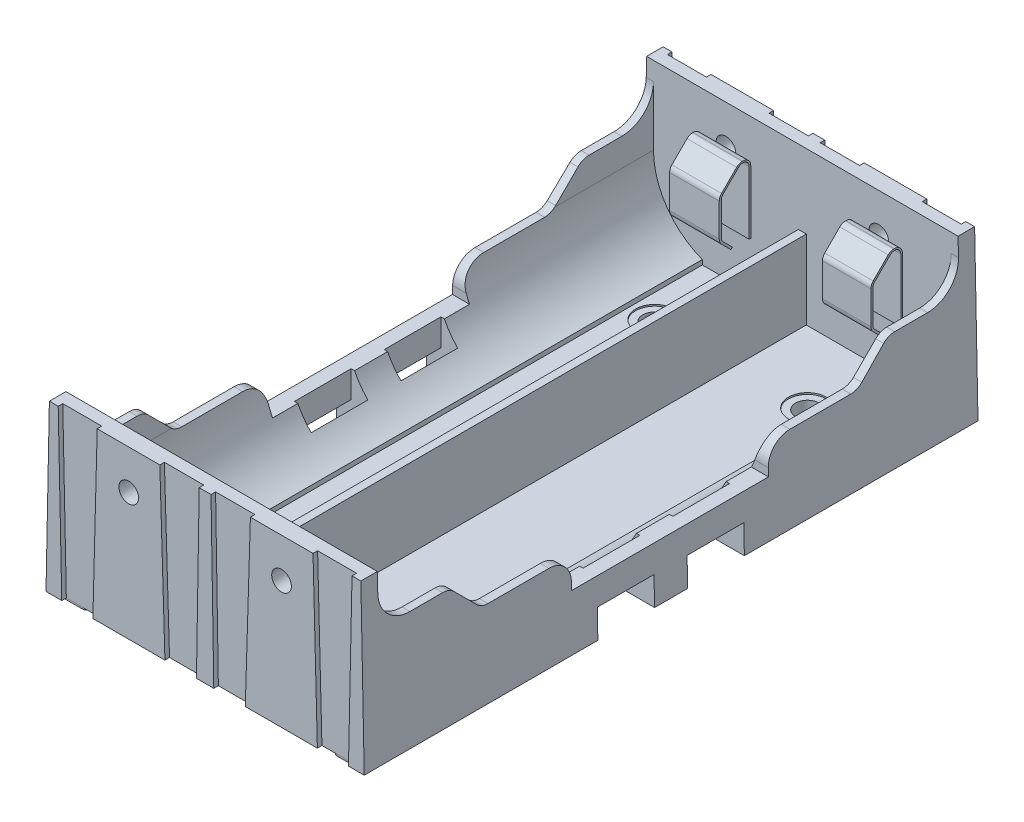
from build123d import *

# Parameters (mm, degrees)
BOSS_EXTRU_1_DEPTH       = 73.72
BOSS_EXTRU_2_DEPTH       = 2.1
BOSS_EXTRU_3_DEPTH       = 2.1
CONG_1_R                 = 4
ENL_V_START              = 17.890763
ENL_V_MAT_EXTRU_1_DEPTH  = 2.167345
ENL_V_START_2            = -20.058108
ENL_V_MAT_EXTRU_2_DEPTH  = 2.167345
ENL_V_START_3            = 16.2
ESQUISSE6_W              = 7.2
ESQUISSE6_H              = 7.148183782
ENL_V_MAT_EXTRU_3_DEPTH  = 4
ENL_V_START_4            = -20.2
ESQUISSE6_2_W            = 7.2
ESQUISSE6_2_H            = 7.148183782
ENL_V_MAT_EXTRU_4_DEPTH  = 4
ESQUISSE7_W              = 2.127027027
ESQUISSE7_H              = 7.2
ENL_V_MAT_EXTRU_5_DEPTH  = 22.14
CONG_2_R                 = 2
CONG_3_R                 = 2.8
ESQUISSE8_R              = 3
BOSS_EXTRU_4_DEPTH       = 0.22
ESQUISSE9_R              = 1.5
ENL_V_MAT_EXTRU_6_DEPTH  = 22.36
ENL_V_MAT_EXTRU_7_DEPTH  = 0.58
ENL_V_START_5            = -77.92
ENL_V_MAT_EXTRU_8_DEPTH  = 0.58
ESQUISSE11_R             = 2.4
ENL_V_MAT_EXTRU_9_DEPTH  = 0.2
BOSS_EXTRU_5_START       = 6
ESQUISSE12_W             = 6.3
ESQUISSE12_H             = 4
ESQUISSE12_W_2           = 6.15
BOSS_EXTRU_5_DEPTH       = 9
CHANFREIN1_SIZE          = 2.5
CHANFREIN2_SIZE          = 1.5
CONG_4_R                 = 1
ENL_V_MAT_EXTRU_10_REACH = 34.9
ENL_V_START_6            = -25.55
ENL_V_MAT_EXTRU_11_DEPTH = 6.3
ESQUISSE14_R             = 1.25
ENL_V_MAT_EXTRU_12_DEPTH = 2.1
ESQUISSE14_2_R           = 1.25
ENL_V_MAT_EXTRU_13_DEPTH = 2.1


with BuildPart() as part:
    # Esquisse1 → Boss.-Extru.1 (new body)
    with BuildSketch(Plane.XY):
        with BuildLine():
            Line((-19.9, 14.8), (-20.2, 0))
            Line((-20.2, 0), (0, 0))
            Line((0, 0), (0, 11.74))
            Line((0, 11.74), (-0.5, 11.74))
            Line((-0.5, 11.74), (-0.5, 1.74))
            Line((-0.5, 1.74), (-12.7, 1.74))
            Line((-12.7, 1.74), (-12.7, 2.34))
            ThreePointArc((-12.7, 2.34), (-17.19797428, 5.832963152), (-18.9, 11.267636339))
            Line((-18.9, 11.267636339), (-18.9, 14.8))
            Line((-18.9, 14.8), (-19.9, 14.8))
        make_face()
        with BuildLine():
            Line((0, 11.74), (0, 0))
            Line((0, 0), (20.2, 0))
            Line((20.2, 0), (19.9, 14.8))
            Line((19.9, 14.8), (18.9, 14.8))
            Line((18.9, 14.8), (18.9, 11.267636339))
            ThreePointArc((18.9, 11.267636339), (17.19797428, 5.832963152), (12.7, 2.34))
            Line((12.7, 2.34), (12.7, 1.74))
            Line((12.7, 1.74), (0.5, 1.74))
            Line((0.5, 1.74), (0.5, 11.74))
            Line((0.5, 11.74), (0, 11.74))
        make_face()
    extrude(amount=BOSS_EXTRU_1_DEPTH)

    # Esquisse2 → Boss.-Extru.2 (add)
    with BuildSketch(Plane.XY.offset(73.72)):
        Polygon((-20.2, 0), (20.2, 0), (19.771486486, 21.14), (-19.771486486, 21.14), align=None)
    extrude(amount=BOSS_EXTRU_2_DEPTH)

    # Esquisse3 → Boss.-Extru.3 (add)
    with BuildSketch(Plane(origin=(0, 0, 0), x_dir=(-1, 0, 0), z_dir=(0, 0, -1))):
        Polygon((-20.2, 0), (20.2, 0), (19.771486486, 21.14), (-19.771486486, 21.14), align=None)
    extrude(amount=BOSS_EXTRU_3_DEPTH)

    # Cong_1
    cong_1_edges = [part.edges().sort_by_distance(p)[0] for p in [
        (19.4, 14.8, 0),
        (-19.4, 14.8, 0),
        (-19.4, 14.8, 73.72),
        (19.4, 14.8, 73.72),
    ]]
    fillet(cong_1_edges, radius=CONG_1_R)

    # Esquisse4 → Enl_v. mat.-Extru.1 (cut)
    with BuildSketch(Plane(origin=(0, 0, 0), x_dir=(0, 0, -1), z_dir=(1, 0, 0)).offset(ENL_V_START)):
        Polygon((-64.72, 14.8), (-60.72, 10.8), (-49.36, 10.8), (-49.36, 7), (-24.36, 7), (-24.36, 10.8), (-13, 10.8), (-9, 14.8), align=None)
    extrude(amount=ENL_V_MAT_EXTRU_1_DEPTH, mode=Mode.SUBTRACT)

    # Esquisse4_2 → Enl_v. mat.-Extru.2 (cut)
    with BuildSketch(Plane(origin=(0, 0, 0), x_dir=(0, 0, -1), z_dir=(1, 0, 0)).offset(ENL_V_START_2)):
        Polygon((-64.72, 14.8), (-60.72, 10.8), (-49.36, 10.8), (-49.36, 7), (-24.36, 7), (-24.36, 10.8), (-13, 10.8), (-9, 14.8), align=None)
    extrude(amount=ENL_V_MAT_EXTRU_2_DEPTH, mode=Mode.SUBTRACT)

    # Esquisse6 → Enl_v. mat.-Extru.3 (cut)
    with BuildSketch(Plane(origin=(0, 0, 0), x_dir=(0, 0, -1), z_dir=(1, 0, 0)).offset(ENL_V_START_3)):
        with Locations((-42.56, 0.025908109)):
            Rectangle(ESQUISSE6_W, ESQUISSE6_H)
        with Locations((-31.16, 0.025908109)):
            Rectangle(ESQUISSE6_W, ESQUISSE6_H)
    extrude(amount=ENL_V_MAT_EXTRU_3_DEPTH, mode=Mode.SUBTRACT)

    # Esquisse6_2 → Enl_v. mat.-Extru.4 (cut)
    with BuildSketch(Plane(origin=(0, 0, 0), x_dir=(0, 0, -1), z_dir=(1, 0, 0)).offset(ENL_V_START_4)):
        with Locations((-42.56, 0.025908109)):
            Rectangle(ESQUISSE6_2_W, ESQUISSE6_2_H)
        with Locations((-31.16, 0.025908109)):
            Rectangle(ESQUISSE6_2_W, ESQUISSE6_2_H)
    extrude(amount=ENL_V_MAT_EXTRU_4_DEPTH, mode=Mode.SUBTRACT)

    # Esquisse7 → Enl_v. mat.-Extru.5 (cut, through all)
    with BuildSketch(Plane.XZ):
        with Locations((17.263513514, 42.56)):
            Rectangle(ESQUISSE7_W, ESQUISSE7_H)
        with Locations((-17.263513514, 42.56)):
            Rectangle(ESQUISSE7_W, ESQUISSE7_H)
        with Locations((17.263513514, 31.16)):
            Rectangle(ESQUISSE7_W, ESQUISSE7_H)
        with Locations((-17.263513514, 31.16)):
            Rectangle(ESQUISSE7_W, ESQUISSE7_H)
    extrude(amount=-ENL_V_MAT_EXTRU_5_DEPTH, mode=Mode.SUBTRACT)

    # Cong_2
    cong_2_edges = [part.edges().sort_by_distance(p)[0] for p in [
        (-19.4, 14.8, 9),
        (19.4, 14.8, 9),
        (19.4, 14.8, 64.72),
        (-19.4, 14.8, 64.72),
        (-19.434798938, 10.8, 60.72),
        (19.434798938, 10.8, 60.72),
        (19.434798938, 10.8, 13),
        (-19.434798938, 10.8, 13),
    ]]
    fillet(cong_2_edges, radius=CONG_2_R)

    # Cong_3
    cong_3_edges = [part.edges().sort_by_distance(p)[0] for p in [
        (19.434798938, 10.8, 49.36),
        (19.434798938, 10.8, 24.36),
        (-19.434798938, 10.8, 24.36),
        (-19.434798938, 10.8, 49.36),
    ]]
    fillet(cong_3_edges, radius=CONG_3_R)

    # Esquisse8 → Boss.-Extru.4 (add)
    with BuildSketch(Plane.XZ):
        with Locations((-9.7, 64.66)):
            Circle(ESQUISSE8_R)
        with Locations((9.7, 64.66)):
            Circle(ESQUISSE8_R)
        with Locations((9.7, 9.06)):
            Circle(ESQUISSE8_R)
        with Locations((-9.7, 9.06)):
            Circle(ESQUISSE8_R)
        with BuildLine():
            Line((-19.1, 75.22), (-16.16, 75.22))
            ThreePointArc((-16.16, 75.22), (-15.66, 74.72), (-16.16, 74.22))
            Line((-16.16, 74.22), (-18.5, 74.22))
            ThreePointArc((-18.5, 74.22), (-18.570710678, 74.190710678), (-18.6, 74.12))
            Line((-18.6, 74.12), (-18.6, 73.42))
            ThreePointArc((-18.6, 73.42), (-19.1, 72.92), (-19.6, 73.42))
            Line((-19.6, 73.42), (-19.6, 74.72))
            ThreePointArc((-19.6, 74.72), (-19.453553391, 75.073553391), (-19.1, 75.22))
        make_face()
        with BuildLine():
            Line((18.6, 73.42), (18.6, 74.12))
            ThreePointArc((18.6, 74.12), (18.570710678, 74.190710678), (18.5, 74.22))
            Line((18.5, 74.22), (16.16, 74.22))
            ThreePointArc((16.16, 74.22), (15.66, 74.72), (16.16, 75.22))
            Line((16.16, 75.22), (19.1, 75.22))
            ThreePointArc((19.1, 75.22), (19.453553391, 75.073553391), (19.6, 74.72))
            Line((19.6, 74.72), (19.6, 73.42))
            ThreePointArc((19.6, 73.42), (19.1, 72.92), (18.6, 73.42))
        make_face()
        with BuildLine():
            Line((19.1, -1.5), (16.16, -1.5))
            ThreePointArc((16.16, -1.5), (15.66, -1), (16.16, -0.5))
            Line((16.16, -0.5), (18.5, -0.5))
            ThreePointArc((18.5, -0.5), (18.570710678, -0.470710678), (18.6, -0.4))
            Line((18.6, -0.4), (18.6, 0.3))
            ThreePointArc((18.6, 0.3), (19.1, 0.8), (19.6, 0.3))
            Line((19.6, 0.3), (19.6, -1))
            ThreePointArc((19.6, -1), (19.453553391, -1.353553391), (19.1, -1.5))
        make_face()
        with BuildLine():
            Line((-18.6, 0.3), (-18.6, -0.4))
            ThreePointArc((-18.6, -0.4), (-18.570710678, -0.470710678), (-18.5, -0.5))
            Line((-18.5, -0.5), (-16.16, -0.5))
            ThreePointArc((-16.16, -0.5), (-15.66, -1), (-16.16, -1.5))
            Line((-16.16, -1.5), (-19.1, -1.5))
            ThreePointArc((-19.1, -1.5), (-19.453553391, -1.353553391), (-19.6, -1))
            Line((-19.6, -1), (-19.6, 0.3))
            ThreePointArc((-19.6, 0.3), (-19.1, 0.8), (-18.6, 0.3))
        make_face()
    extrude(amount=BOSS_EXTRU_4_DEPTH)

    # Esquisse9 → Enl_v. mat.-Extru.6 (cut, through all)
    with BuildSketch(Plane(origin=(0, -0.22, 0), x_dir=(-1, 0, 0), z_dir=(0, -1, 0))):
        with Locations((9.7, -64.66)):
            Circle(ESQUISSE9_R)
        with Locations((-9.7, -64.66)):
            Circle(ESQUISSE9_R)
        with Locations((-9.7, -9.06)):
            Circle(ESQUISSE9_R)
        with Locations((9.7, -9.06)):
            Circle(ESQUISSE9_R)
    extrude(amount=-ENL_V_MAT_EXTRU_6_DEPTH, mode=Mode.SUBTRACT)

    # Esquisse10 → Enl_v. mat.-Extru.7 (cut)
    with BuildSketch(Plane.XY.offset(75.82)):
        Polygon((-0.75, 21.14), (-1.1, 0), (-5.1, 0), (-5.75, 21.14), align=None)
        Polygon((-18.65, 21.14), (-18.2, 0), (-14.25, 0), (-13.7, 21.14), align=None)
        Polygon((5.1, 0), (1.1, 0), (0.75, 21.14), (5.75, 21.14), align=None)
        Polygon((18.2, 0), (14.25, 0), (13.7, 21.14), (18.65, 21.14), align=None)
    extrude(amount=-ENL_V_MAT_EXTRU_7_DEPTH, mode=Mode.SUBTRACT)

    # Esquisse10_2 → Enl_v. mat.-Extru.8 (cut)
    with BuildSketch(Plane.XY.offset(75.82).offset(ENL_V_START_5)):
        Polygon((-0.75, 21.14), (-1.1, 0), (-5.1, 0), (-5.75, 21.14), align=None)
        Polygon((-18.65, 21.14), (-18.2, 0), (-14.25, 0), (-13.7, 21.14), align=None)
        Polygon((5.1, 0), (1.1, 0), (0.75, 21.14), (5.75, 21.14), align=None)
        Polygon((18.2, 0), (14.25, 0), (13.7, 21.14), (18.65, 21.14), align=None)
    extrude(amount=ENL_V_MAT_EXTRU_8_DEPTH, mode=Mode.SUBTRACT)

    # Esquisse11 → Enl_v. mat.-Extru.9 (cut)
    with BuildSketch(Plane(origin=(0, 1.74, 0), x_dir=(1, 0, 0), z_dir=(0, 1, 0))):
        with Locations((-9.7, -9.06)):
            Circle(ESQUISSE11_R)
        with Locations((9.7, -9.06)):
            Circle(ESQUISSE11_R)
        with Locations((9.7, -64.66)):
            Circle(ESQUISSE11_R)
        with Locations((-9.7, -64.66)):
            Circle(ESQUISSE11_R)
    extrude(amount=-ENL_V_MAT_EXTRU_9_DEPTH, mode=Mode.SUBTRACT)

    # Esquisse12 → Boss.-Extru.5 (add)
    with BuildSketch(Plane(origin=(0, 1.74, 0), x_dir=(1, 0, 0), z_dir=(0, 1, 0)).offset(BOSS_EXTRU_5_START)):
        with Locations((-9.7, -71.72)):
            Rectangle(ESQUISSE12_W, ESQUISSE12_H)
        with Locations((9.625, -71.72)):
            Rectangle(ESQUISSE12_W_2, ESQUISSE12_H)
        with Locations((9.625, -2)):
            Rectangle(ESQUISSE12_W_2, ESQUISSE12_H)
        with Locations((-9.7, -2)):
            Rectangle(ESQUISSE12_W, ESQUISSE12_H)
    extrude(amount=BOSS_EXTRU_5_DEPTH)

    # Chanfrein1
    chanfrein1_edges = [part.edges().sort_by_distance(p)[0] for p in [
        (-9.7, 16.74, 69.72),
        (9.625, 16.74, 69.72),
        (9.625, 16.74, 4),
        (-9.7, 16.74, 4),
    ]]
    chamfer(chanfrein1_edges, length=CHANFREIN1_SIZE)

    # Chanfrein2
    chanfrein2_edges = [part.edges().sort_by_distance(p)[0] for p in [
        (-9.7, 7.74, 69.72),
        (9.625, 7.74, 69.72),
        (9.625, 7.74, 4),
        (-9.7, 7.74, 4),
    ]]
    chamfer(chanfrein2_edges, length=CHANFREIN2_SIZE)

    # Cong_4
    cong_4_edges = [part.edges().sort_by_distance(p)[0] for p in [
        (-9.7, 14.24, 4),
        (-9.7, 16.74, 1.5),
        (9.625, 16.74, 1.5),
        (9.625, 14.24, 4),
        (9.625, 14.24, 69.72),
        (9.625, 16.74, 72.22),
        (-9.7, 16.74, 72.22),
        (-9.7, 14.24, 69.72),
        (9.625, 9.24, 4),
        (-9.7, 9.24, 4),
        (-9.7, 9.24, 69.72),
        (9.625, 9.24, 69.72),
    ]]
    fillet(cong_4_edges, radius=CONG_4_R)

    # Esquisse13 → Enl_v. mat.-Extru.10 (cut, up to next)
    with BuildSketch(Plane(origin=(12.7, 0, 0), x_dir=(0, 0, -1), z_dir=(1, 0, 0)), mode=Mode.PRIVATE) as enl_v_mat_extru_10_sk1:
        with BuildLine():
            Line((-72.72, 16.74), (-72.72, 17.106019535))
            Line((-72.72, 17.106019535), (-73.72, 17.106019535))
            Line((-73.72, 17.106019535), (-73.72, 15.74))
            ThreePointArc((-73.72, 15.74), (-73.427106781, 16.447106781), (-72.72, 16.74))
        make_face()
    enl_v_mat_extru_10_tool1 = extrude(enl_v_mat_extru_10_sk1.sketch, amount=-ENL_V_MAT_EXTRU_10_REACH, mode=Mode.PRIVATE) & part.part
    add(enl_v_mat_extru_10_tool1.solids().sort_by_distance((12.7, 16.77281, 73.322245))[0], mode=Mode.SUBTRACT)
    # Esquisse13 → Enl_v. mat.-Extru.10 (cut, up to next)
    with BuildSketch(Plane(origin=(12.7, 0, 0), x_dir=(0, 0, -1), z_dir=(1, 0, 0)), mode=Mode.PRIVATE) as enl_v_mat_extru_10_sk2:
        with BuildLine():
            Line((-70.197207794, 14.348578644), (-72.154314575, 16.305685425))
            ThreePointArc((-72.154314575, 16.305685425), (-73.026146746, 16.479103626), (-73.52, 15.74))
            Line((-73.52, 15.74), (-73.52, 6.535067032))
            Line((-73.52, 6.535067032), (-72.553577604, 6.535067032))
            Line((-72.553577604, 6.535067032), (-70.870571572, 7.428556502))
            Line((-70.870571572, 7.428556502), (-71.38532211, 7.94330704))
            Line((-71.38532211, 7.94330704), (-70.197207794, 9.131421356))
            ThreePointArc((-70.197207794, 9.131421356), (-70.036939065, 9.371280459), (-69.980660172, 9.654213562))
            Line((-69.980660172, 9.654213562), (-69.980660172, 13.825786438))
            ThreePointArc((-69.980660172, 13.825786438), (-70.036939065, 14.108719541), (-70.197207794, 14.348578644))
        make_face()
    enl_v_mat_extru_10_tool2 = extrude(enl_v_mat_extru_10_sk2.sketch, amount=-ENL_V_MAT_EXTRU_10_REACH, mode=Mode.PRIVATE) & part.part
    add(enl_v_mat_extru_10_tool2.solids().sort_by_distance((12.7, 11.523685, 71.952093))[0], mode=Mode.SUBTRACT)
    # Esquisse13 → Enl_v. mat.-Extru.10 (cut, up to next)
    with BuildSketch(Plane(origin=(12.7, 0, 0), x_dir=(0, 0, -1), z_dir=(1, 0, 0)), mode=Mode.PRIVATE) as enl_v_mat_extru_10_sk3:
        with BuildLine():
            Line((-0.2, 6.535067032), (-1.166422396, 6.535067032))
            Line((-1.166422396, 6.535067032), (-2.849428428, 7.428556502))
            Line((-2.849428428, 7.428556502), (-2.33467789, 7.94330704))
            Line((-2.33467789, 7.94330704), (-3.522792206, 9.131421356))
            ThreePointArc((-3.522792206, 9.131421356), (-3.683060935, 9.371280459), (-3.739339828, 9.654213562))
            Line((-3.739339828, 9.654213562), (-3.739339828, 13.825786438))
            ThreePointArc((-3.739339828, 13.825786438), (-3.683060935, 14.108719541), (-3.522792206, 14.348578644))
            Line((-3.522792206, 14.348578644), (-1.565685425, 16.305685425))
            ThreePointArc((-1.565685425, 16.305685425), (-0.693853254, 16.479103626), (-0.2, 15.74))
            Line((-0.2, 15.74), (-0.2, 6.535067032))
        make_face()
    enl_v_mat_extru_10_tool3 = extrude(enl_v_mat_extru_10_sk3.sketch, amount=-ENL_V_MAT_EXTRU_10_REACH, mode=Mode.PRIVATE) & part.part
    add(enl_v_mat_extru_10_tool3.solids().sort_by_distance((12.7, 11.523685, 1.767907))[0], mode=Mode.SUBTRACT)
    # Esquisse13 → Enl_v. mat.-Extru.10 (cut, up to next)
    with BuildSketch(Plane(origin=(12.7, 0, 0), x_dir=(0, 0, -1), z_dir=(1, 0, 0)), mode=Mode.PRIVATE) as enl_v_mat_extru_10_sk4:
        with BuildLine():
            Line((0, 17.106019535), (0, 15.74))
            ThreePointArc((0, 15.74), (-0.292893219, 16.447106781), (-1, 16.74))
            Line((-1, 16.74), (-1, 17.106019535))
            Line((-1, 17.106019535), (0, 17.106019535))
        make_face()
    enl_v_mat_extru_10_tool4 = extrude(enl_v_mat_extru_10_sk4.sketch, amount=-ENL_V_MAT_EXTRU_10_REACH, mode=Mode.PRIVATE) & part.part
    add(enl_v_mat_extru_10_tool4.solids().sort_by_distance((12.7, 16.77281, 0.397755))[0], mode=Mode.SUBTRACT)

    # Esquisse13_3 → Enl_v. mat.-Extru.11 (cut)
    with BuildSketch(Plane(origin=(12.7, 0, 0), x_dir=(0, 0, -1), z_dir=(1, 0, 0)).offset(ENL_V_START_6)):
        with BuildLine():
            Line((-72.72, 16.74), (-72.72, 17.106019535))
            Line((-72.72, 17.106019535), (-73.72, 17.106019535))
            Line((-73.72, 17.106019535), (-73.72, 15.74))
            ThreePointArc((-73.72, 15.74), (-73.427106781, 16.447106781), (-72.72, 16.74))
        make_face()
        with BuildLine():
            Line((-70.197207794, 14.348578644), (-72.154314575, 16.305685425))
            ThreePointArc((-72.154314575, 16.305685425), (-73.026146746, 16.479103626), (-73.52, 15.74))
            Line((-73.52, 15.74), (-73.52, 6.535067032))
            Line((-73.52, 6.535067032), (-72.553577604, 6.535067032))
            Line((-72.553577604, 6.535067032), (-70.870571572, 7.428556502))
            Line((-70.870571572, 7.428556502), (-71.38532211, 7.94330704))
            Line((-71.38532211, 7.94330704), (-70.197207794, 9.131421356))
            ThreePointArc((-70.197207794, 9.131421356), (-70.036939065, 9.371280459), (-69.980660172, 9.654213562))
            Line((-69.980660172, 9.654213562), (-69.980660172, 13.825786438))
            ThreePointArc((-69.980660172, 13.825786438), (-70.036939065, 14.108719541), (-70.197207794, 14.348578644))
        make_face()
        with BuildLine():
            Line((-0.2, 6.535067032), (-1.166422396, 6.535067032))
            Line((-1.166422396, 6.535067032), (-2.849428428, 7.428556502))
            Line((-2.849428428, 7.428556502), (-2.33467789, 7.94330704))
            Line((-2.33467789, 7.94330704), (-3.522792206, 9.131421356))
            ThreePointArc((-3.522792206, 9.131421356), (-3.683060935, 9.371280459), (-3.739339828, 9.654213562))
            Line((-3.739339828, 9.654213562), (-3.739339828, 13.825786438))
            ThreePointArc((-3.739339828, 13.825786438), (-3.683060935, 14.108719541), (-3.522792206, 14.348578644))
            Line((-3.522792206, 14.348578644), (-1.565685425, 16.305685425))
            ThreePointArc((-1.565685425, 16.305685425), (-0.693853254, 16.479103626), (-0.2, 15.74))
            Line((-0.2, 15.74), (-0.2, 6.535067032))
        make_face()
        with BuildLine():
            Line((0, 17.106019535), (0, 15.74))
            ThreePointArc((0, 15.74), (-0.292893219, 16.447106781), (-1, 16.74))
            Line((-1, 16.74), (-1, 17.106019535))
            Line((-1, 17.106019535), (0, 17.106019535))
        make_face()
    extrude(amount=ENL_V_MAT_EXTRU_11_DEPTH, mode=Mode.SUBTRACT)

    # Esquisse14 → Enl_v. mat.-Extru.12 (cut)
    with BuildSketch(Plane(origin=(0, 0, -2.1), x_dir=(-1, 0, 0), z_dir=(0, 0, -1))):
        with Locations((9.7, 16.14)):
            Circle(ESQUISSE14_R)
        with Locations((-9.7, 16.14)):
            Circle(ESQUISSE14_R)
    extrude(amount=-ENL_V_MAT_EXTRU_12_DEPTH, mode=Mode.SUBTRACT)

    # Esquisse14_2 → Enl_v. mat.-Extru.13 (cut)
    with BuildSketch(Plane(origin=(0, 0, -2.1), x_dir=(-1, 0, 0), z_dir=(0, 0, -1)).offset(ENL_V_START_5)):
        with Locations((9.7, 16.14)):
            Circle(ESQUISSE14_2_R)
        with Locations((-9.7, 16.14)):
            Circle(ESQUISSE14_2_R)
    extrude(amount=ENL_V_MAT_EXTRU_13_DEPTH, mode=Mode.SUBTRACT)


solid = part.part
